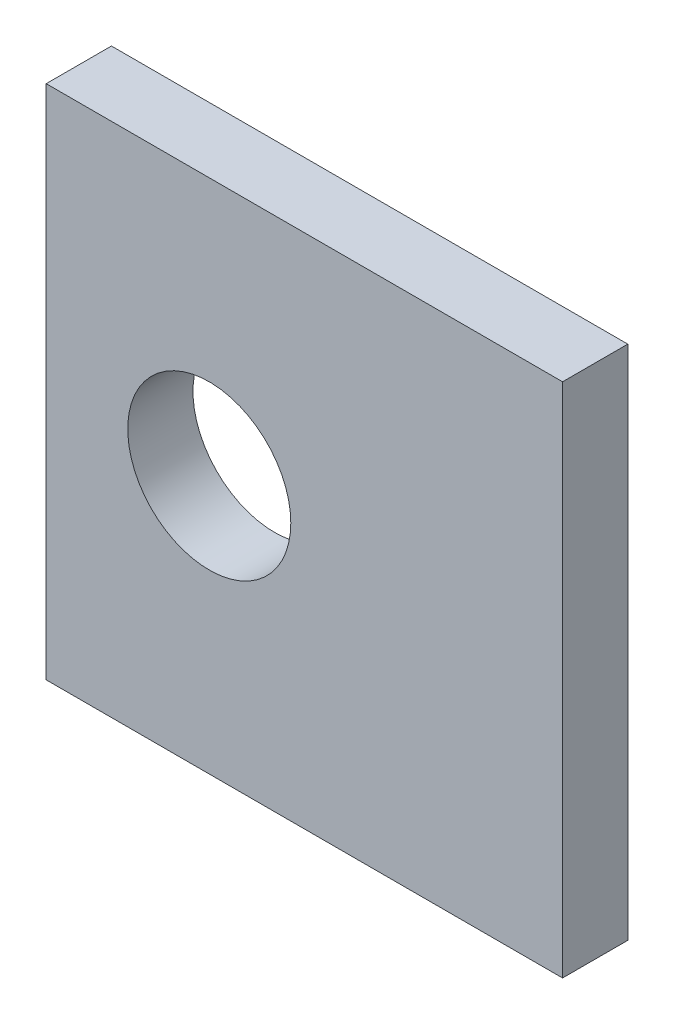
from build123d import *

# Parameters (mm, degrees)
SKETCH1_W           = 38
SKETCH1_H           = 4.8
BOSS_EXTRUDE1_DEPTH = 38
SKETCH2_R           = 2
CUT_EXTRUDE1_DEPTH  = 10
SKETCH3_R           = 6
CUT_EXTRUDE2_DEPTH  = 5.8


with BuildPart() as part:
    # Sketch1 → Boss-Extrude1 (new body)
    with BuildSketch(Plane(origin=(0, 0, 0), x_dir=(1, 0, 0), z_dir=(0, 1, 0))):
        Rectangle(SKETCH1_W, SKETCH1_H)
    extrude(amount=BOSS_EXTRUDE1_DEPTH)

    # Sketch2 → Cut-Extrude1 (cut)
    with BuildSketch(Plane.XZ):
        with Locations((7.75, 0)):
            Circle(SKETCH2_R)
        with Locations((-7.75, 0)):
            Circle(SKETCH2_R)
    extrude(amount=-CUT_EXTRUDE1_DEPTH, mode=Mode.SUBTRACT)

    # Sketch3 → Cut-Extrude2 (cut, through all)
    with BuildSketch(Plane.XY.offset(2.4)):
        with Locations((-7, 19)):
            Circle(SKETCH3_R)
    extrude(amount=-CUT_EXTRUDE2_DEPTH, mode=Mode.SUBTRACT)


solid = part.part
